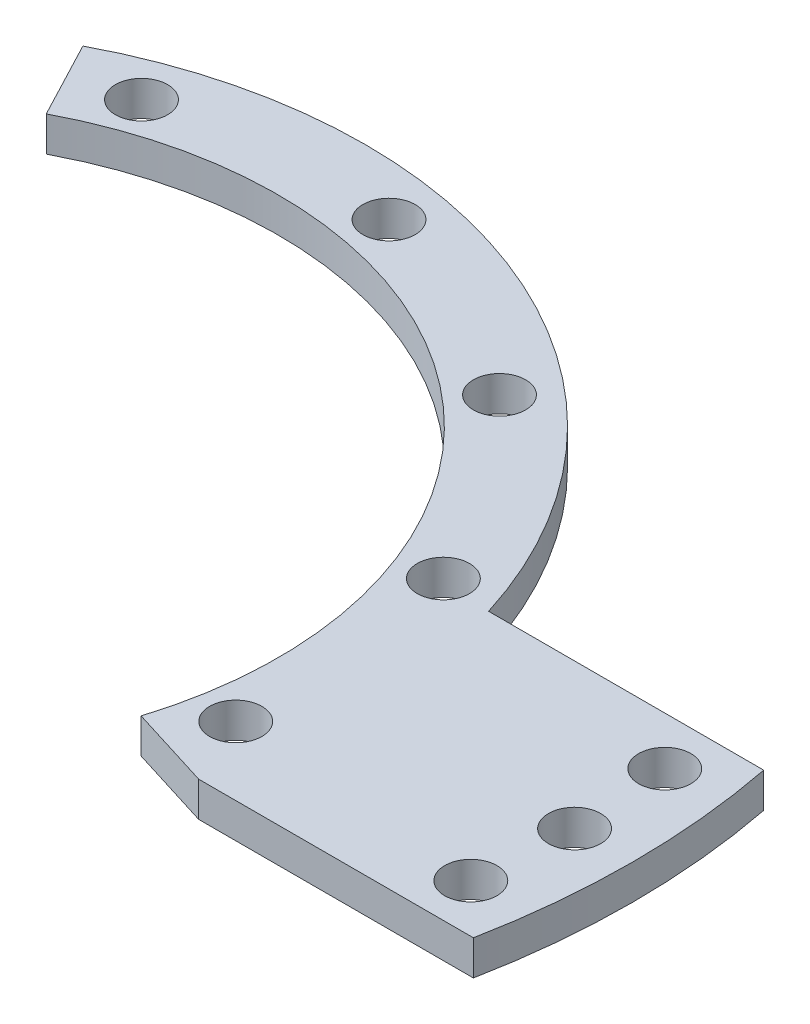
from build123d import *

# Parameters (mm, degrees)
SKETCH1_R                       = 42
BOSS_EXTRUDE1_DEPTH             = 3
SKETCH2_W                       = 70
SKETCH2_H                       = 25
BOSS_EXTRUDE2_DEPTH             = 3
SKETCH3_R                       = 34.5
CUT_EXTRUDE1_DEPTH              = 1
CUT_EXTRUDE1_DEPTH_BACK         = 4
CUT_EXTRUDE2_DEPTH              = 1
CUT_EXTRUDE2_DEPTH_BACK         = 4
CUT_EXTRUDE3_START              = -4
SKETCH5_R                       = 2.25
CUT_EXTRUDE3_DEPTH              = 5
CIRPATTERN1_COUNT               = 12
SKETCH6_R                       = 122.183782822
SKETCH6_R_2                     = 65
CUT_EXTRUDE4_DEPTH              = 4
CUT_EXTRUDE4_DEPTH_BACK         = 1
CUT_EXTRUDE5_START              = -4
SKETCH7_R                       = 2.25
CUT_EXTRUDE5_DEPTH              = 5
CIRPATTERN2_COUNT               = 2
CIRPATTERN2_ANGLE               = 8
CIRPATTERN2_THE_OTHER_WAY_COUNT = 2
CIRPATTERN2_THE_OTHER_WAY_ANGLE = 8


with BuildPart() as part:
    # Sketch1 → Boss-Extrude1 (new body)
    with BuildSketch(Plane(origin=(0, 0, 0), x_dir=(1, 0, 0), z_dir=(0, 1, 0))):
        Circle(SKETCH1_R)
    extrude(amount=BOSS_EXTRUDE1_DEPTH)

    # Sketch2 → Boss-Extrude2 (add)
    with BuildSketch(Plane(origin=(0, 0, 0), x_dir=(1, 0, 0), z_dir=(0, 1, 0))):
        with Locations((35, 0)):
            Rectangle(SKETCH2_W, SKETCH2_H)
    extrude(amount=BOSS_EXTRUDE2_DEPTH)

    # Sketch3 → Cut-Extrude1 (cut, two sides)
    with BuildSketch(Plane(origin=(0, 3, 0), x_dir=(1, 0, 0), z_dir=(0, 1, 0))) as cut_extrude1_sk:
        Circle(SKETCH3_R)
    extrude(amount=CUT_EXTRUDE1_DEPTH, mode=Mode.SUBTRACT)
    extrude(cut_extrude1_sk.sketch, amount=-CUT_EXTRUDE1_DEPTH_BACK, mode=Mode.SUBTRACT)

    # Sketch4 → Cut-Extrude2 (cut, two sides)
    with BuildSketch(Plane(origin=(0, 3, 0), x_dir=(1, 0, 0), z_dir=(0, 1, 0))) as cut_extrude2_sk:
        with BuildLine():
            Line((0, 0), (40.099953579, -12.489744711))
            ThreePointArc((40.099953579, -12.489744711), (-26.884607378, -32.267907991), (-19.52336592, 37.186532282))
            Line((-19.52336592, 37.186532282), (0, 0))
        make_face()
    extrude(amount=CUT_EXTRUDE2_DEPTH, mode=Mode.SUBTRACT)
    extrude(cut_extrude2_sk.sketch, amount=-CUT_EXTRUDE2_DEPTH_BACK, mode=Mode.SUBTRACT)

    # Sketch5 → Cut-Extrude3 (cut)
    with BuildSketch(Plane(origin=(0, 3, 0), x_dir=(1, 0, 0), z_dir=(0, 1, 0)).offset(CUT_EXTRUDE3_START)):
        with Locations((-12.996765446, 35.70831959)):
            Circle(SKETCH5_R)
    cut_extrude3 = extrude(amount=CUT_EXTRUDE3_DEPTH, mode=Mode.SUBTRACT)

    # CirPattern1: Cut-Extrude3 ×12 about axis
    cirpattern1_axis = Axis((0, 0, 0), (0, -1, 0))
    for i in range(1, CIRPATTERN1_COUNT):
        add(cut_extrude3.rotate(cirpattern1_axis, i * 360 / CIRPATTERN1_COUNT), mode=Mode.SUBTRACT)

    # Sketch6 → Cut-Extrude4 (cut, two sides)
    with BuildSketch(Plane(origin=(0, 0, 0), x_dir=(1, 0, 0), z_dir=(0, 1, 0))) as cut_extrude4_sk:
        Circle(SKETCH6_R)
        Circle(SKETCH6_R_2, mode=Mode.SUBTRACT)
    extrude(amount=CUT_EXTRUDE4_DEPTH, mode=Mode.SUBTRACT)
    extrude(cut_extrude4_sk.sketch, amount=-CUT_EXTRUDE4_DEPTH_BACK, mode=Mode.SUBTRACT)

    # Sketch7 → Cut-Extrude5 (cut)
    with BuildSketch(Plane(origin=(0, 3, 0), x_dir=(1, 0, 0), z_dir=(0, 1, 0)).offset(CUT_EXTRUDE5_START)):
        with Locations((60, 0)):
            Circle(SKETCH7_R)
    cut_extrude5 = extrude(amount=CUT_EXTRUDE5_DEPTH, mode=Mode.SUBTRACT)

    # CirPattern2: Cut-Extrude5 ×2 about axis
    cirpattern2_axis = Axis((0, 3, 0), (0, 1, 0))
    for i in range(1, CIRPATTERN2_COUNT):
        add(cut_extrude5.rotate(cirpattern2_axis, i * CIRPATTERN2_ANGLE / (CIRPATTERN2_COUNT - 1)), mode=Mode.SUBTRACT)

    # CirPattern2 the other way: Cut-Extrude5 ×2 about axis
    cirpattern2_the_other_way_axis = Axis((0, 3, 0), (0, -1, 0))
    for i in range(1, CIRPATTERN2_THE_OTHER_WAY_COUNT):
        add(cut_extrude5.rotate(cirpattern2_the_other_way_axis, i * CIRPATTERN2_THE_OTHER_WAY_ANGLE / (CIRPATTERN2_THE_OTHER_WAY_COUNT - 1)), mode=Mode.SUBTRACT)


solid = part.part
